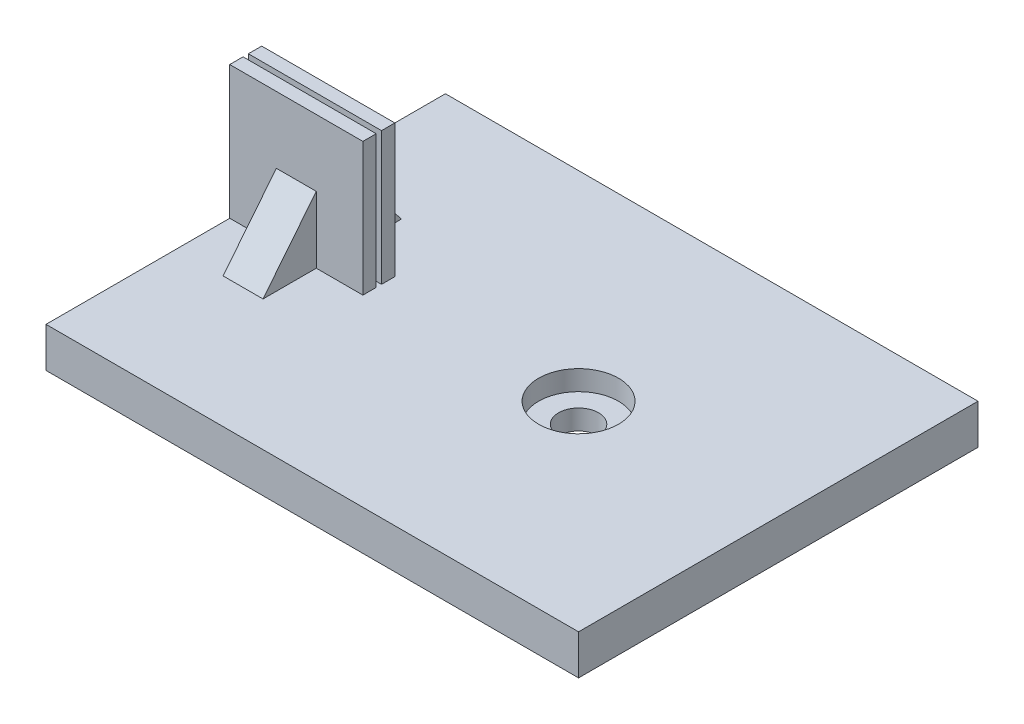
from build123d import *

# Parameters (mm, degrees)
SKETCH1_W           = 40
SKETCH1_H           = 30
BOSS_EXTRUDE1_DEPTH = 3
SKETCH2_R           = 3
CUT_EXTRUDE1_DEPTH  = 1.5
SKETCH3_R           = 1.5
CUT_EXTRUDE2_DEPTH  = 30.193321154
SKETCH4_R           = 5
SKETCH4_R_2         = 3
CUT_EXTRUDE3_DEPTH  = 0.5
SKETCH6_W           = 10
SKETCH6_H           = 1
BOSS_EXTRUDE2_DEPTH = 10
RIB5_REACH          = 42.237
SKETCH10_WALL_W     = 88.876722392
SKETCH10_WALL_H     = 3


with BuildPart() as part:
    # Sketch1 → Boss-Extrude1 (new body)
    with BuildSketch(Plane(origin=(0, 0, 0), x_dir=(1, 0, 0), z_dir=(0, 1, 0))):
        with Locations((-5, 0)):
            Rectangle(SKETCH1_W, SKETCH1_H)
    extrude(amount=BOSS_EXTRUDE1_DEPTH)

    # Sketch2 → Cut-Extrude1 (cut)
    with BuildSketch(Plane(origin=(0, 3, 0), x_dir=(1, 0, 0), z_dir=(0, 1, 0))):
        with Locations(Location((0, 0, 0), (0, 0, 270))):
            Circle(SKETCH2_R)
    extrude(amount=-CUT_EXTRUDE1_DEPTH, mode=Mode.SUBTRACT)

    # Sketch3 → Cut-Extrude2 (cut, through all)
    with BuildSketch(Plane(origin=(0, 1.5, 0), x_dir=(1, 0, 0), z_dir=(0, 1, 0))):
        with Locations(Location((0, 0, 0), (0, 0, 270))):
            Circle(SKETCH3_R)
    extrude(amount=-CUT_EXTRUDE2_DEPTH, mode=Mode.SUBTRACT)

    # Sketch4 → Cut-Extrude3 (cut)
    with BuildSketch(Plane.XZ):
        with Locations(Location((0, 0, 0), (0, 0, 270))):
            Circle(SKETCH4_R)
        with Locations(Location((0, 0, 0), (0, 0, 90))):
            Circle(SKETCH4_R_2, mode=Mode.SUBTRACT)
    extrude(amount=-CUT_EXTRUDE3_DEPTH, mode=Mode.SUBTRACT)

    # Sketch6 → Boss-Extrude2 (add)
    with BuildSketch(Plane(origin=(0, 3, 0), x_dir=(1, 0, 0), z_dir=(0, 1, 0))):
        with Locations((-20, -0.7)):
            Rectangle(SKETCH6_W, SKETCH6_H)
        with Locations((-20, 0.7)):
            Rectangle(SKETCH6_W, SKETCH6_H)
    extrude(amount=BOSS_EXTRUDE2_DEPTH)

    # Sketch10 wall → Rib5 (add, up to next)
    with BuildSketch(Plane(origin=(-20, 5.5, 3.2), x_dir=(0, -0.780868809443, 0.624695047554), z_dir=(0, -0.624695047554, -0.780868809443)), mode=Mode.PRIVATE) as rib5_sk1:
        Rectangle(SKETCH10_WALL_W, SKETCH10_WALL_H)
    rib5_tool1 = extrude(rib5_sk1.sketch, amount=RIB5_REACH, mode=Mode.PRIVATE) - part.part
    rib5 = rib5_tool1.solids().sort_by_distance((-20, 5.5, 3.2))[0]
    add(rib5)

    # Mirror1: Rib5 across plane
    add(rib5.mirror(Plane.XY))


solid = part.part
